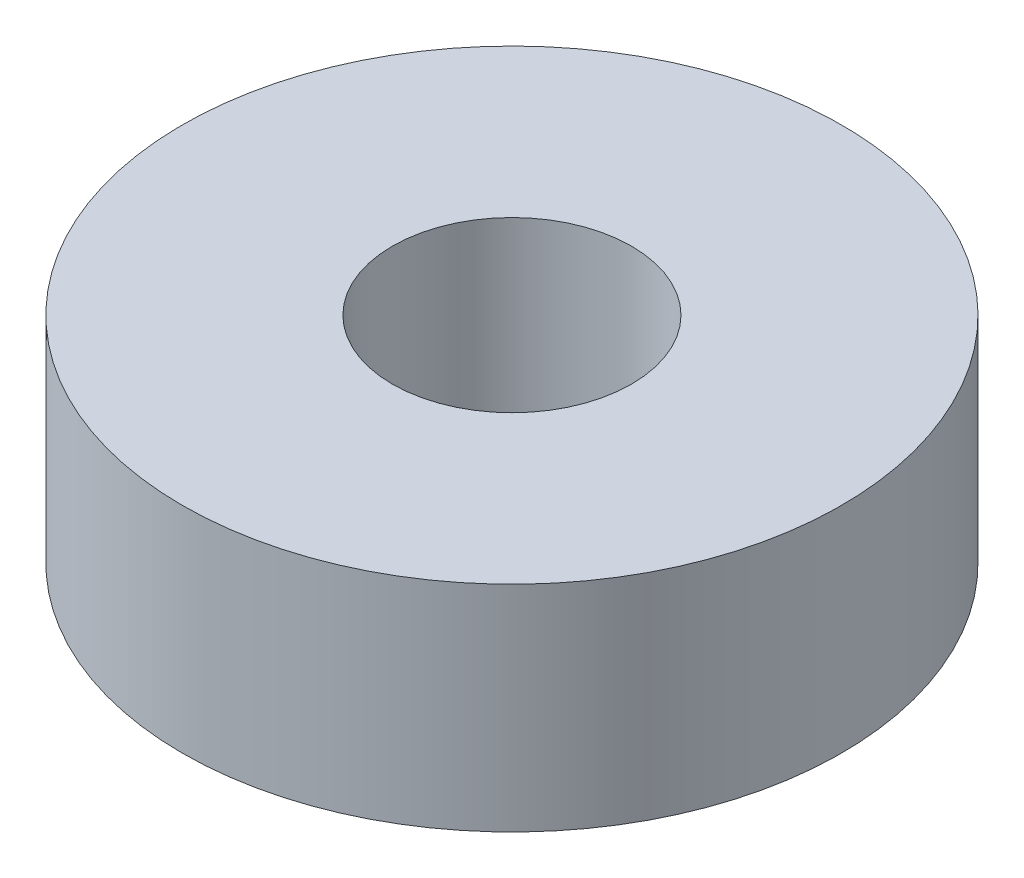
from build123d import *

# Parameters (mm, degrees)
SKETCH1_R           = 10.75
SKETCH1_R_2         = 3.9
BOSS_EXTRUDE1_DEPTH = 7


with BuildPart() as part:
    # Sketch1 → Boss-Extrude1 (new body)
    with BuildSketch(Plane(origin=(0, 0, 0), x_dir=(1, 0, 0), z_dir=(0, 1, 0))):
        Circle(SKETCH1_R)
        Circle(SKETCH1_R_2, mode=Mode.SUBTRACT)
    extrude(amount=BOSS_EXTRUDE1_DEPTH)


solid = part.part
